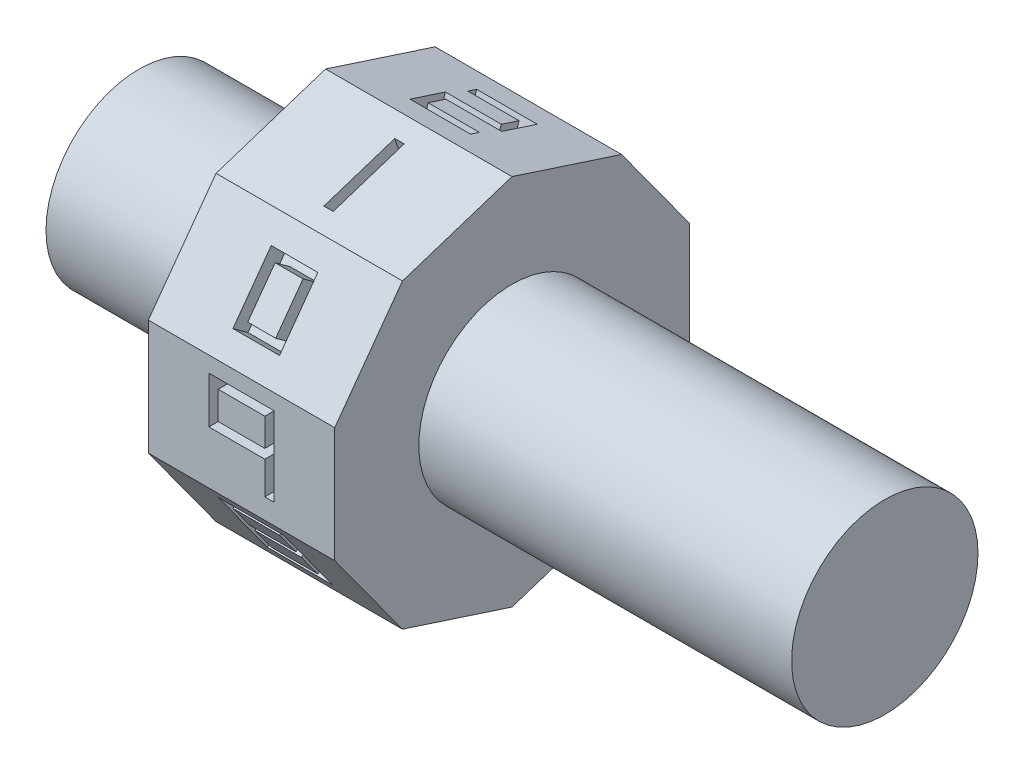
from build123d import *

# Parameters (mm, degrees)
BOSS_EXTRUDE1_DEPTH      = 25.4
SKETCH2_R                = 12.7
BOSS_EXTRUDE2_DEPTH      = 50.8
SKETCH3_R                = 12.7
BOSS_EXTRUDE3_DEPTH      = 25.4
SKETCH4_W                = 6.35
SKETCH4_H                = 8.89
SKETCH4_W_2              = 3.81
SKETCH4_H_2              = 6.35
CUT_EXTRUDE1_DEPTH       = 2.54
SKETCH5_W                = 1.27
SKETCH5_H                = 10.16
CUT_EXTRUDE2_DEPTH       = 2.54
CUT_EXTRUDE3_DEPTH       = 2.54
CUT_EXTRUDE4_DEPTH       = 2.54
CUT_EXTRUDE5_DEPTH       = 2.54
CUT_EXTRUDE6_DEPTH       = 2.54
SKETCH11_W               = 6.35
SKETCH11_H               = 3.81
CUT_EXTRUDE7_DEPTH       = 8.464872704
CUT_EXTRUDE7_DEPTH_BACK  = 2.54
CUT_EXTRUDE8_DEPTH       = 2.54
SKETCH13_W               = 8.89
SKETCH13_H               = 11.43
SKETCH13_W_2             = 6.35
SKETCH13_H_2             = 3.81
CUT_EXTRUDE9_DEPTH       = 2.54
SKETCH14_W               = 6.35
SKETCH14_H               = 3.81
CUT_EXTRUDE10_DEPTH      = 1
CUT_EXTRUDE10_DEPTH_BACK = 2.54


with BuildPart() as part:
    # Sketch1 → Boss-Extrude1 (new body)
    with BuildSketch(Plane(origin=(0, 0, 0), x_dir=(0, 0, -1), z_dir=(1, 0, 0))):
        Polygon((0, 25.4), (-14.929745408, 20.549031657), (-24.156835514, 7.849031657), (-24.156835514, -7.849031657), (-14.929745408, -20.549031657), (0, -25.4), (14.929745408, -20.549031657), (24.156835514, -7.849031657), (24.156835514, 7.849031657), (14.929745408, 20.549031657), align=None)
    extrude(amount=BOSS_EXTRUDE1_DEPTH)

    # Sketch2 → Boss-Extrude2 (add)
    with BuildSketch(Plane(origin=(25.4, 0, 0), x_dir=(0, 0, -1), z_dir=(1, 0, 0))):
        Circle(SKETCH2_R)
    extrude(amount=BOSS_EXTRUDE2_DEPTH)

    # Sketch3 → Boss-Extrude3 (add)
    with BuildSketch(Plane.ZY):
        Circle(SKETCH3_R)
    extrude(amount=BOSS_EXTRUDE3_DEPTH)

    # Sketch4 → Cut-Extrude1 (cut)
    with BuildSketch(Plane(origin=(0, 14.199031657, 19.543290461), x_dir=(1, 0, 0), z_dir=(0, 0.587785252, 0.809016994))):
        with Locations((12.7, 0)):
            Rectangle(SKETCH4_W, SKETCH4_H)
        with Locations((12.7, 0)):
            Rectangle(SKETCH4_W_2, SKETCH4_H_2, mode=Mode.SUBTRACT)
    extrude(amount=-CUT_EXTRUDE1_DEPTH, mode=Mode.SUBTRACT)

    # Sketch5 → Cut-Extrude2 (cut)
    with BuildSketch(Plane(origin=(0, 22.974515829, 7.464872704), x_dir=(1, 0, 0), z_dir=(0, 0.951056516, 0.309016994))):
        with Locations((12.7, 0)):
            Rectangle(SKETCH5_W, SKETCH5_H)
    extrude(amount=-CUT_EXTRUDE2_DEPTH, mode=Mode.SUBTRACT)

    # Sketch6 → Cut-Extrude3 (cut)
    with BuildSketch(Plane(origin=(0, 22.974515829, -7.464872704), x_dir=(1, 0, 0), z_dir=(0, 0.951056516, -0.309016994))):
        Polygon((8.89, 3.175), (15.875, 3.175), (15.875, 0.635), (8.255, 0.635), (8.255, -4.445), (16.51, -4.445), (16.51, -3.175), (9.525, -3.175), (9.525, -0.635), (17.145, -0.635), (17.145, 4.445), (8.89, 4.445), align=None)
    extrude(amount=-CUT_EXTRUDE3_DEPTH, mode=Mode.SUBTRACT)

    # Sketch8 → Cut-Extrude4 (cut)
    with BuildSketch(Plane(origin=(0, 14.199031657, -19.543290461), x_dir=(-1, 0, 0), z_dir=(0, 0.587785252, -0.809016994))):
        Polygon((-8.89, -5.715), (-8.89, -4.445), (-15.875, -4.445), (-15.875, -0.635), (-8.89, -0.635), (-8.89, 0.635), (-15.875, 0.635), (-15.875, 4.445), (-8.89, 4.445), (-8.89, 5.715), (-17.145, 5.715), (-17.145, -5.715), align=None)
    extrude(amount=-CUT_EXTRUDE4_DEPTH, mode=Mode.SUBTRACT)

    # Sketch9 → Cut-Extrude5 (cut)
    with BuildSketch(Plane(origin=(0, 0, -24.156835514), x_dir=(-1, 0, 0), z_dir=(0, 0, -1))):
        Polygon((-9.525, -5.08), (-8.255, -5.08), (-8.255, 0.635), (-15.875, 0.635), (-15.875, 5.08), (-17.145, 5.08), (-17.145, -5.08), (-15.875, -5.08), (-15.875, -0.635), (-9.525, -0.635), align=None)
    extrude(amount=-CUT_EXTRUDE5_DEPTH, mode=Mode.SUBTRACT)

    # Sketch10 → Cut-Extrude6 (cut)
    with BuildSketch(Plane(origin=(0, -14.199031657, -19.543290461), x_dir=(-1, 0, 0), z_dir=(0, -0.587785252, -0.809016994))):
        Polygon((-8.89, 5.715), (-17.145, 5.715), (-17.145, -0.635), (-9.525, -0.635), (-9.525, -4.445), (-16.51, -4.445), (-16.51, -5.715), (-8.255, -5.715), (-8.255, 0.635), (-15.875, 0.635), (-15.875, 4.445), (-8.89, 4.445), align=None)
    extrude(amount=-CUT_EXTRUDE6_DEPTH, mode=Mode.SUBTRACT)

    # Sketch11 → Cut-Extrude7 (cut, two sides)
    with BuildSketch(Plane(origin=(0, -22.974515829, -7.464872704), x_dir=(1, 0, 0), z_dir=(0, -0.951056516, -0.309016994))) as cut_extrude7_sk:
        Polygon((17.145, 0.635), (9.525, 0.635), (9.525, 4.445), (16.51, 4.445), (16.51, 5.715), (8.255, 5.715), (8.255, -5.715), (17.145, -5.715), align=None)
        with Locations((12.7, -2.54)):
            Rectangle(SKETCH11_W, SKETCH11_H, mode=Mode.SUBTRACT)
    extrude(amount=CUT_EXTRUDE7_DEPTH, mode=Mode.SUBTRACT)
    extrude(cut_extrude7_sk.sketch, amount=-CUT_EXTRUDE7_DEPTH_BACK, mode=Mode.SUBTRACT)

    # Sketch12 → Cut-Extrude8 (cut)
    with BuildSketch(Plane(origin=(0, -22.974515829, 7.464872704), x_dir=(1, 0, 0), z_dir=(0, -0.951056516, 0.309016994))):
        Polygon((8.89, 4.445), (15.875, 4.445), (15.875, -5.08), (17.145, -5.08), (17.145, 5.715), (8.89, 5.715), align=None)
    extrude(amount=-CUT_EXTRUDE8_DEPTH, mode=Mode.SUBTRACT)

    # Sketch13 → Cut-Extrude9 (cut)
    with BuildSketch(Plane(origin=(0, -14.199031657, 19.543290461), x_dir=(1, 0, 0), z_dir=(0, -0.587785252, 0.809016994))):
        with Locations((12.7, 0)):
            Rectangle(SKETCH13_W, SKETCH13_H)
        with Locations((12.7, -2.54)):
            Rectangle(SKETCH13_W_2, SKETCH13_H_2, mode=Mode.SUBTRACT)
        with Locations((12.7, 2.54)):
            Rectangle(SKETCH13_W_2, SKETCH13_H_2, mode=Mode.SUBTRACT)
    extrude(amount=-CUT_EXTRUDE9_DEPTH, mode=Mode.SUBTRACT)

    # Sketch14 → Cut-Extrude10 (cut, two sides)
    with BuildSketch(Plane.XY.offset(24.156835514)) as cut_extrude10_sk:
        Polygon((15.875, -0.635), (15.875, -5.08), (17.145, -5.08), (17.145, 5.715), (8.255, 5.715), (8.255, -0.635), align=None)
        with Locations((12.7, 2.54)):
            Rectangle(SKETCH14_W, SKETCH14_H, mode=Mode.SUBTRACT)
    extrude(amount=CUT_EXTRUDE10_DEPTH, mode=Mode.SUBTRACT)
    extrude(cut_extrude10_sk.sketch, amount=-CUT_EXTRUDE10_DEPTH_BACK, mode=Mode.SUBTRACT)


solid = part.part
